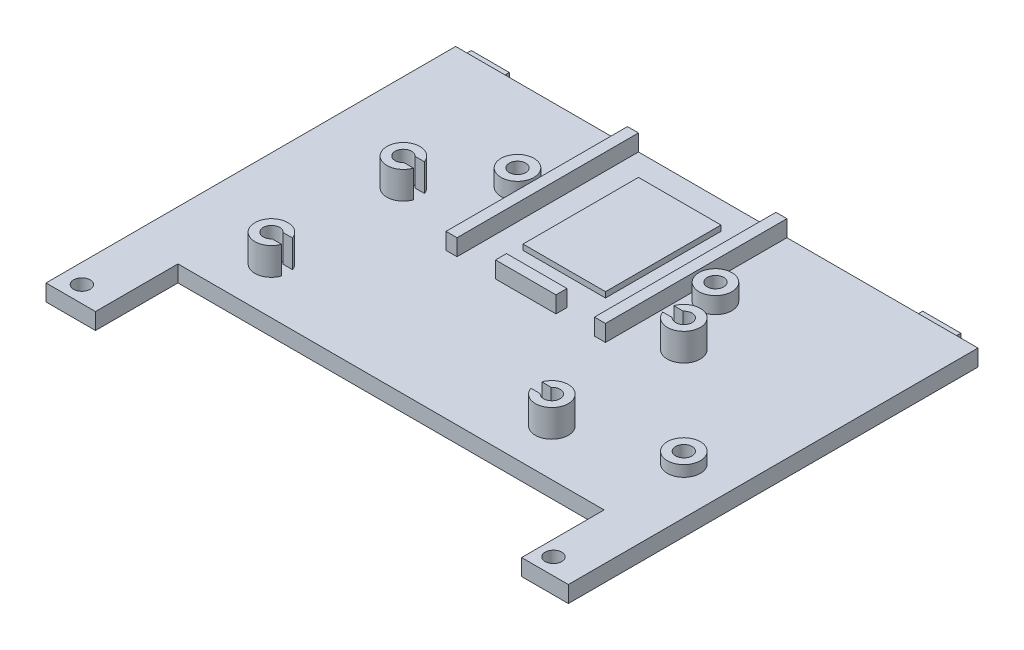
from build123d import *

# Parameters (mm, degrees)
SKETCH1_W            = 106.5
SKETCH1_H            = 74.5
BOSS_EXTRUDE1_DEPTH  = 3
SKETCH2_W            = 6.93
SKETCH2_H            = 1.85
BOSS_EXTRUDE2_DEPTH  = 3
SKETCH3_W            = 6.93
SKETCH3_H            = 1.85
CUT_EXTRUDE1_DEPTH   = 1.07
SKETCH4_W            = 5
SKETCH4_H            = 64.5
SKETCH4_W_2          = 78.5
SKETCH4_H_2          = 15
CUT_EXTRUDE2_DEPTH   = 3
SKETCH5_R            = 3.5
CUT_EXTRUDE3_DEPTH   = 3
BOSS_EXTRUDE5_DEPTH  = 5
SKETCH9_R            = 3
SKETCH9_R_2          = 1.5
BOSS_EXTRUDE6_DEPTH  = 2
SKETCH10_W           = 15
SKETCH10_H           = 21
BOSS_EXTRUDE7_DEPTH  = 1
BOSS_EXTRUDE8_DEPTH  = 2
SKETCH12_W           = 5
SKETCH12_H           = 5
CUT_EXTRUDE4_DEPTH   = 4
SKETCH14_W           = 4
SKETCH14_H           = 75.31405771
CUT_EXTRUDE5_DEPTH   = 10
SKETCH15_R           = 3
SKETCH15_R_2         = 1.5
BOSS_EXTRUDE9_DEPTH  = 3
SKETCH16_R           = 1.5
CUT_EXTRUDE6_DEPTH   = 3
SKETCH17_R           = 1.5
CUT_EXTRUDE7_DEPTH   = 3
SKETCH18_W           = 7
SKETCH18_H           = 2
CUT_EXTRUDE8_DEPTH   = 3
SKETCH19_R           = 1.5
CUT_EXTRUDE9_DEPTH   = 3
SKETCH20_W           = 3
SKETCH20_H           = 74.5
CUT_EXTRUDE10_DEPTH  = 8
SKETCH21_W           = 1
SKETCH21_H           = 15
BOSS_EXTRUDE10_DEPTH = 3


with BuildPart() as part:
    # Sketch1 → Boss-Extrude1 (new body)
    with BuildSketch(Plane(origin=(0, 0, 0), x_dir=(1, 0, 0), z_dir=(0, 1, 0))):
        Rectangle(SKETCH1_W, SKETCH1_H)
    extrude(amount=BOSS_EXTRUDE1_DEPTH)

    # Sketch2 → Boss-Extrude2 (add)
    with BuildSketch(Plane(origin=(0, 3, 0), x_dir=(1, 0, 0), z_dir=(0, 1, 0))):
        with Locations((-43.8, 38.175)):
            Rectangle(SKETCH2_W, SKETCH2_H)
        with Locations((38.315, 38.175)):
            Rectangle(SKETCH2_W, SKETCH2_H)
    extrude(amount=-BOSS_EXTRUDE2_DEPTH)

    # Sketch3 → Cut-Extrude1 (cut)
    with BuildSketch(Plane(origin=(0, 3, 0), x_dir=(1, 0, 0), z_dir=(0, 1, 0))):
        with Locations((-43.8, 38.175)):
            Rectangle(SKETCH3_W, SKETCH3_H)
        with Locations((38.315, 38.175)):
            Rectangle(SKETCH3_W, SKETCH3_H)
    extrude(amount=-CUT_EXTRUDE1_DEPTH, mode=Mode.SUBTRACT)

    # Sketch4 → Cut-Extrude2 (cut)
    with BuildSketch(Plane(origin=(0, 3, 0), x_dir=(1, 0, 0), z_dir=(0, 1, 0))):
        with Locations((-50.75, 0)):
            Rectangle(SKETCH4_W, SKETCH4_H)
        with Locations((0, -29.75)):
            Rectangle(SKETCH4_W_2, SKETCH4_H_2)
    extrude(amount=-CUT_EXTRUDE2_DEPTH, mode=Mode.SUBTRACT)

    # Sketch5 → Cut-Extrude3 (cut)
    with BuildSketch(Plane(origin=(0, 3, 0), x_dir=(1, 0, 0), z_dir=(0, 1, 0))):
        with Locations((-53.25, -37.25)):
            Circle(SKETCH5_R)
        with Locations((53.25, -37.25)):
            Circle(SKETCH5_R)
        with Locations((53.25, 37.25)):
            Circle(SKETCH5_R)
        with Locations((-53.25, 37.25)):
            Circle(SKETCH5_R)
    extrude(amount=-CUT_EXTRUDE3_DEPTH, mode=Mode.SUBTRACT)

    # Sketch6 → Boss-Extrude5 (add)
    with BuildSketch(Plane(origin=(0, 3, 0), x_dir=(1, 0, 0), z_dir=(0, 1, 0))):
        with BuildLine():
            Line((-29.091687605, 12.75), (-32.408312395, 12.75))
            ThreePointArc((-32.408312395, 12.75), (-32.871320344, 12.371320344), (-33.25, 11.908312395))
            Line((-33.25, 11.908312395), (-33.25, 8.591687605))
            ThreePointArc((-33.25, 8.591687605), (-30.382155065, 7.272637055), (-27.921572875, 9.25))
            Line((-27.921572875, 9.25), (-29.631966011, 9.25))
            ThreePointArc((-29.631966011, 9.25), (-32.25, 10.25), (-29.631966011, 11.25))
            Line((-29.631966011, 11.25), (-27.921572875, 11.25))
            ThreePointArc((-27.921572875, 11.25), (-28.384580824, 12.09520788), (-29.091687605, 12.75))
        make_face()
        with BuildLine():
            Line((-33.25, 8.591687605), (-33.25, 11.908312395))
            ThreePointArc((-33.25, 11.908312395), (-33.75, 10.25), (-33.25, 8.591687605))
        make_face()
        with BuildLine():
            ThreePointArc((-29.091687605, 12.75), (-30.75, 13.25), (-32.408312395, 12.75))
            Line((-32.408312395, 12.75), (-29.091687605, 12.75))
        make_face()
        with BuildLine():
            ThreePointArc((-27.921572875, -12.75), (-30.382155065, -10.772637055), (-33.25, -12.091687605))
            Line((-33.25, -12.091687605), (-33.25, -15.408312395))
            ThreePointArc((-33.25, -15.408312395), (-32.871320344, -15.871320344), (-32.408312395, -16.25))
            Line((-32.408312395, -16.25), (-29.091687605, -16.25))
            ThreePointArc((-29.091687605, -16.25), (-28.384580824, -15.59520788), (-27.921572875, -14.75))
            Line((-27.921572875, -14.75), (-29.631966011, -14.75))
            ThreePointArc((-29.631966011, -14.75), (-32.25, -13.75), (-29.631966011, -12.75))
            Line((-29.631966011, -12.75), (-27.921572875, -12.75))
        make_face()
        with BuildLine():
            Line((-33.25, -15.408312395), (-33.25, -12.091687605))
            ThreePointArc((-33.25, -12.091687605), (-33.75, -13.75), (-33.25, -15.408312395))
        make_face()
        with BuildLine():
            Line((-29.091687605, -16.25), (-32.408312395, -16.25))
            ThreePointArc((-32.408312395, -16.25), (-30.75, -16.75), (-29.091687605, -16.25))
        make_face()
        with BuildLine():
            Line((22.75, -15.408312395), (22.75, -12.091687605))
            ThreePointArc((22.75, -12.091687605), (19.882155065, -10.772637055), (17.421572875, -12.75))
            Line((17.421572875, -12.75), (19.131966011, -12.75))
            ThreePointArc((19.131966011, -12.75), (20.785233135, -12.348741462), (21.75, -13.75))
            ThreePointArc((21.75, -13.75), (20.785233135, -15.151258538), (19.131966011, -14.75))
            Line((19.131966011, -14.75), (17.421572875, -14.75))
            ThreePointArc((17.421572875, -14.75), (17.884580824, -15.59520788), (18.591687605, -16.25))
            Line((18.591687605, -16.25), (21.908312395, -16.25))
            ThreePointArc((21.908312395, -16.25), (22.371320344, -15.871320344), (22.75, -15.408312395))
        make_face()
        with BuildLine():
            Line((21.908312395, -16.25), (18.591687605, -16.25))
            ThreePointArc((18.591687605, -16.25), (20.25, -16.75), (21.908312395, -16.25))
        make_face()
        with BuildLine():
            ThreePointArc((23.25, -13.75), (23.122281323, -12.883974596), (22.75, -12.091687605))
            Line((22.75, -12.091687605), (22.75, -15.408312395))
            ThreePointArc((22.75, -15.408312395), (23.122281323, -14.616025404), (23.25, -13.75))
        make_face()
        with BuildLine():
            Line((21.908312395, 12.75), (18.591687605, 12.75))
            ThreePointArc((18.591687605, 12.75), (17.884580824, 12.09520788), (17.421572875, 11.25))
            Line((17.421572875, 11.25), (19.131966011, 11.25))
            ThreePointArc((19.131966011, 11.25), (20.785233135, 11.651258538), (21.75, 10.25))
            ThreePointArc((21.75, 10.25), (20.785233135, 8.848741462), (19.131966011, 9.25))
            Line((19.131966011, 9.25), (17.421572875, 9.25))
            ThreePointArc((17.421572875, 9.25), (19.882155065, 7.272637055), (22.75, 8.591687605))
            Line((22.75, 8.591687605), (22.75, 11.908312395))
            ThreePointArc((22.75, 11.908312395), (22.371320344, 12.371320344), (21.908312395, 12.75))
        make_face()
        with BuildLine():
            ThreePointArc((23.25, 10.25), (23.122281323, 11.116025404), (22.75, 11.908312395))
            Line((22.75, 11.908312395), (22.75, 8.591687605))
            ThreePointArc((22.75, 8.591687605), (23.122281323, 9.383974596), (23.25, 10.25))
        make_face()
        with BuildLine():
            ThreePointArc((21.908312395, 12.75), (20.25, 13.25), (18.591687605, 12.75))
            Line((18.591687605, 12.75), (21.908312395, 12.75))
        make_face()
    extrude(amount=BOSS_EXTRUDE5_DEPTH)

    # Sketch9 → Boss-Extrude6 (add)
    with BuildSketch(Plane(origin=(0, 3, 0), x_dir=(1, 0, 0), z_dir=(0, 1, 0))):
        with Locations((38.25, -7.75)):
            Circle(SKETCH9_R)
        with Locations((38.25, -7.75)):
            Circle(SKETCH9_R_2, mode=Mode.SUBTRACT)
    extrude(amount=BOSS_EXTRUDE6_DEPTH)

    # Sketch10 → Boss-Extrude7 (add)
    with BuildSketch(Plane(origin=(0, 3, 0), x_dir=(1, 0, 0), z_dir=(0, 1, 0))):
        with Locations((-2.5, 21.75)):
            Rectangle(SKETCH10_W, SKETCH10_H)
        Polygon((-15, 6.25), (-15, 37.25), (-17, 37.25), (-17, 4.25), (12, 4.25), (12, 37.25), (10, 37.25), (10, 6.25), align=None)
    extrude(amount=BOSS_EXTRUDE7_DEPTH)

    # Sketch11 → Boss-Extrude8 (add)
    with BuildSketch(Plane(origin=(0, 4, 0), x_dir=(1, 0, 0), z_dir=(0, 1, 0))):
        Polygon((-15, 37.25), (-17, 37.25), (-17, 4.25), (12, 4.25), (12, 37.25), (10, 37.25), (10, 6.25), (-15, 6.25), align=None)
    extrude(amount=BOSS_EXTRUDE8_DEPTH)

    # Sketch12 → Cut-Extrude4 (cut)
    with BuildSketch(Plane(origin=(0, 3, 0), x_dir=(1, 0, 0), z_dir=(0, 1, 0))):
        with Locations((-50.75, 34.75)):
            Rectangle(SKETCH12_W, SKETCH12_H)
        with Locations((-50.75, -34.75)):
            Rectangle(SKETCH12_W, SKETCH12_H)
    extrude(amount=-CUT_EXTRUDE4_DEPTH, mode=Mode.SUBTRACT)

    # Sketch14 → Cut-Extrude5 (cut)
    with BuildSketch(Plane(origin=(0, 3, 0), x_dir=(1, 0, 0), z_dir=(0, 1, 0))):
        with Locations((51.75, 0.407028855)):
            Rectangle(SKETCH14_W, SKETCH14_H)
    extrude(amount=-CUT_EXTRUDE5_DEPTH, mode=Mode.SUBTRACT)

    # Sketch15 → Boss-Extrude9 (add)
    with BuildSketch(Plane(origin=(0, 3, 0), x_dir=(1, 0, 0), z_dir=(0, 1, 0))):
        with Locations((15.5, 20.75)):
            Circle(SKETCH15_R)
        with Locations((15.5, 20.75)):
            Circle(SKETCH15_R_2, mode=Mode.SUBTRACT)
        with Locations((-20.5, 20.75)):
            Circle(SKETCH15_R)
        with Locations((-20.5, 20.75)):
            Circle(SKETCH15_R_2, mode=Mode.SUBTRACT)
    extrude(amount=BOSS_EXTRUDE9_DEPTH)

    # Sketch16 → Cut-Extrude6 (cut)
    with BuildSketch(Plane(origin=(0, 3, 0), x_dir=(1, 0, 0), z_dir=(0, 1, 0))):
        with Locations((15.5, 20.75)):
            Circle(SKETCH16_R)
        with Locations((-20.5, 20.75)):
            Circle(SKETCH16_R)
    extrude(amount=-CUT_EXTRUDE6_DEPTH, mode=Mode.SUBTRACT)

    # Sketch17 → Cut-Extrude7 (cut)
    with BuildSketch(Plane(origin=(0, 3, 0), x_dir=(1, 0, 0), z_dir=(0, 1, 0))):
        with Locations((38.25, -7.75)):
            Circle(SKETCH17_R)
    extrude(amount=-CUT_EXTRUDE7_DEPTH, mode=Mode.SUBTRACT)

    # Sketch18 → Cut-Extrude8 (cut)
    with BuildSketch(Plane(origin=(0, 6, 0), x_dir=(1, 0, 0), z_dir=(0, 1, 0))):
        with Locations((6.5, 5.25)):
            Rectangle(SKETCH18_W, SKETCH18_H)
        with Locations((-11.5, 5.25)):
            Rectangle(SKETCH18_W, SKETCH18_H)
    extrude(amount=-CUT_EXTRUDE8_DEPTH, mode=Mode.SUBTRACT)

    # Sketch19 → Cut-Extrude9 (cut)
    with BuildSketch(Plane(origin=(0, 3, 0), x_dir=(1, 0, 0), z_dir=(0, 1, 0))):
        with Locations((41.035, -34.25)):
            Circle(SKETCH19_R)
        with Locations((-44.73, -34.25)):
            Circle(SKETCH19_R)
    extrude(amount=-CUT_EXTRUDE9_DEPTH, mode=Mode.SUBTRACT)

    # Sketch20 → Cut-Extrude10 (cut)
    with BuildSketch(Plane(origin=(0, 3, 0), x_dir=(1, 0, 0), z_dir=(0, 1, 0))):
        with Locations((48.25, 0)):
            Rectangle(SKETCH20_W, SKETCH20_H)
    extrude(amount=-CUT_EXTRUDE10_DEPTH, mode=Mode.SUBTRACT)

    # Sketch21 → Boss-Extrude10 (add)
    with BuildSketch(Plane(origin=(0, 3, 0), x_dir=(1, 0, 0), z_dir=(0, 1, 0))):
        with Locations((38.75, -29.75)):
            Rectangle(SKETCH21_W, SKETCH21_H)
    extrude(amount=-BOSS_EXTRUDE10_DEPTH)


solid = part.part
